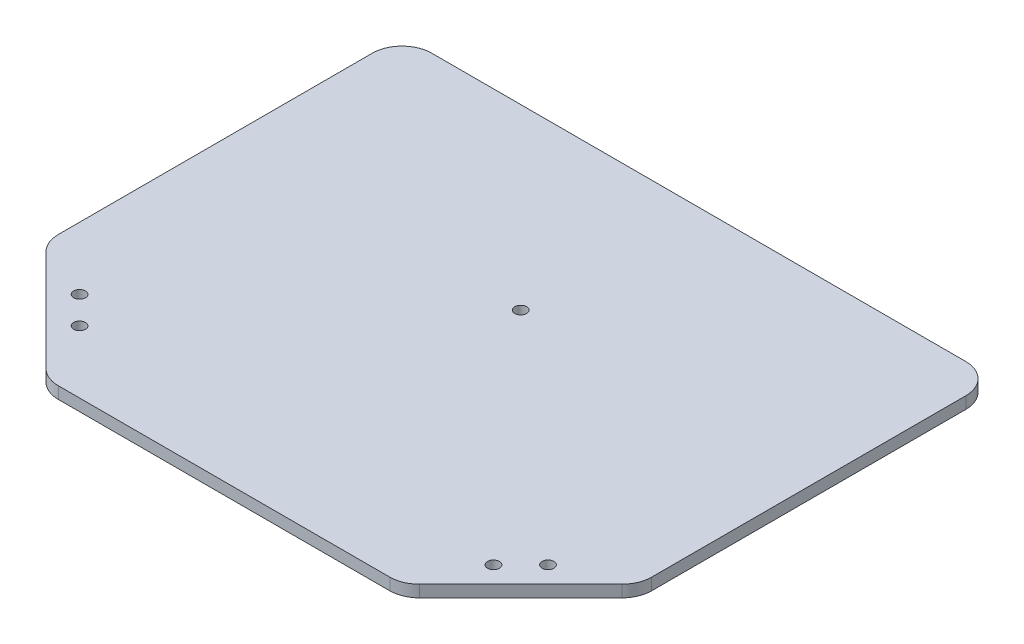
from build123d import *

# Parameters (mm, degrees)
EXTRUDE_1_DEPTH     = 4
SKETCH_2_R          = 2
CUT_EXTRUDE_1_DEPTH = 5
FILLET_1_R          = 10
SKETCH_4_R          = 2
CUT_EXTRUDE_2_DEPTH = 5


with BuildPart() as part:
    # 草图1 → 凸台-拉伸1 (new body)
    with BuildSketch(Plane(origin=(0, 0, 0), x_dir=(1, 0, 0), z_dir=(0, 1, 0))):
        Polygon((-100, 60), (-100, -60), (-60, -100), (60, -100), (100, -60), (100, 60), align=None)
    extrude(amount=EXTRUDE_1_DEPTH)

    # 草图2 → 切除-拉伸1 (cut, through all)
    with BuildSketch(Plane(origin=(0, 4, 0), x_dir=(1, 0, 0), z_dir=(0, 1, 0))):
        Circle(SKETCH_2_R)
    extrude(amount=-CUT_EXTRUDE_1_DEPTH, mode=Mode.SUBTRACT)

    # 圆角1
    fillet_1_edges = [part.edges().sort_by_distance(p)[0] for p in [
        (100, 2, -60),
        (100, 2, 60),
        (60, 2, 100),
        (-60, 2, 100),
        (-100, 2, 60),
        (-100, 2, -60),
    ]]
    fillet(fillet_1_edges, radius=FILLET_1_R)

    # 草图4 → 切除-拉伸2 (cut, through all)
    with BuildSketch(Plane(origin=(0, 0, 0), x_dir=(1, 0, 0), z_dir=(0, 1, 0))):
        with Locations((-78.939339828, -69.746951673)):
            Circle(SKETCH_4_R)
        with Locations((-69.746951673, -78.939339828)):
            Circle(SKETCH_4_R)
        with Locations((69.746951673, -78.939339828)):
            Circle(SKETCH_4_R)
        with Locations((78.939339828, -69.746951673)):
            Circle(SKETCH_4_R)
    extrude(amount=CUT_EXTRUDE_2_DEPTH, mode=Mode.SUBTRACT)


solid = part.part
